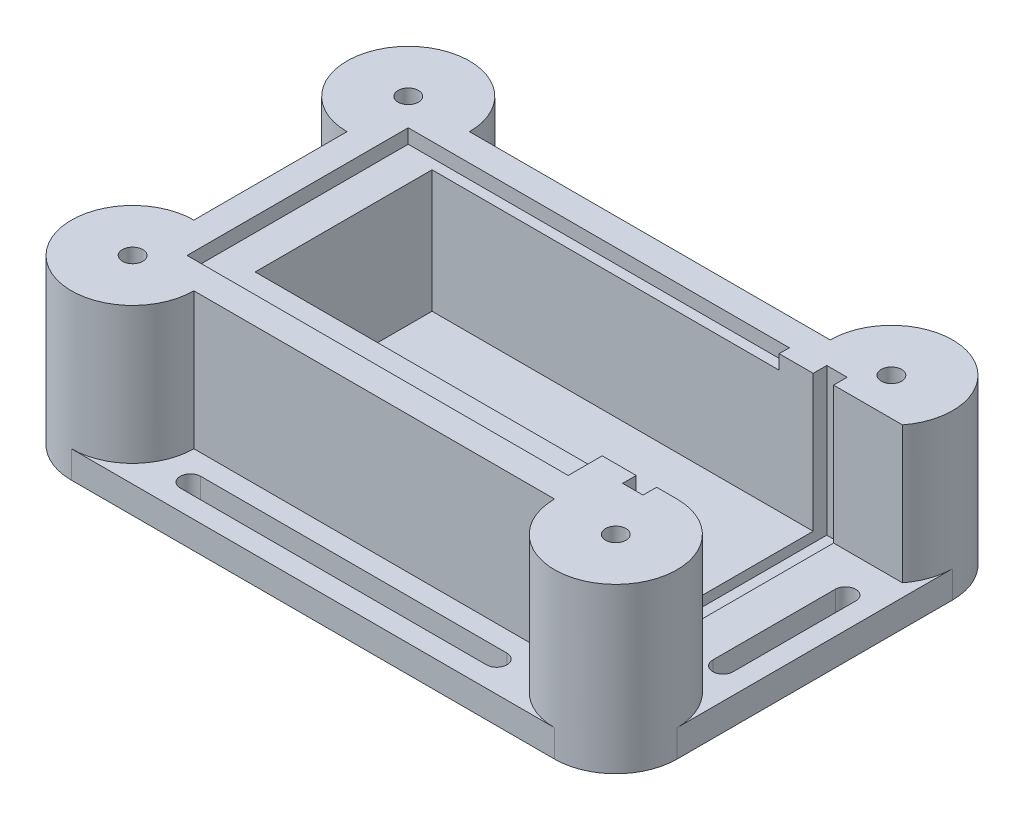
from build123d import *

# Parameters (mm, degrees)
BOSS_EXTRUDE1_DEPTH = 56
SKETCH2_W           = 40.5
SKETCH2_H           = 24.1
BOSS_EXTRUDE2_DEPTH = 4
SKETCH3_W           = 26
SKETCH3_H           = 18
BOSS_EXTRUDE4_DEPTH = 5
BOSS_EXTRUDE5_DEPTH = 11
SKETCH6_W           = 3
SKETCH6_H           = 30
CUT_EXTRUDE1_DEPTH  = 21.6
BOSS_EXTRUDE6_DEPTH = 24.1
BOSS_EXTRUDE7_DEPTH = 4
SKETCH9_R           = 1.5
CUT_EXTRUDE2_DEPTH  = 20


with BuildPart() as part:
    # Sketch1 → Boss-Extrude1 (new body)
    with BuildSketch(Plane(origin=(0, 0, 0), x_dir=(0, 0, -1), z_dir=(1, 0, 0))):
        Polygon((0, 0), (0, -18), (26, -18), (26, 0), (27.5, 0), (27.5, 2.1), (31.5, 2.1), (31.5, -22), (-9, -22), (-9, 2.1), (-5, 2.1), (-5, 0), align=None)
    extrude(amount=-BOSS_EXTRUDE1_DEPTH)

    # Sketch2 → Boss-Extrude2 (add)
    with BuildSketch(Plane.ZY.offset(56)):
        with Locations((-11.25, -9.95)):
            Rectangle(SKETCH2_W, SKETCH2_H)
    extrude(amount=BOSS_EXTRUDE2_DEPTH)

    # Sketch3 → Boss-Extrude4 (add)
    with BuildSketch(Plane(origin=(-56, 0, 0), x_dir=(0, 0, -1), z_dir=(1, 0, 0))):
        with Locations((13, -9)):
            Rectangle(SKETCH3_W, SKETCH3_H)
    extrude(amount=BOSS_EXTRUDE4_DEPTH)

    # Sketch5 → Boss-Extrude5 (add)
    with BuildSketch(Plane(origin=(0, 0, 0), x_dir=(0, 0, -1), z_dir=(1, 0, 0))):
        Polygon((0, 0), (0, 2.1), (-5, 2.1), (-9, 2.1), (-9, -22), (31.5, -22), (31.5, 2.1), (27.5, 2.1), (26, 2.1), (26, 0), (26, -18), (0, -18), align=None)
    extrude(amount=BOSS_EXTRUDE5_DEPTH)

    # Sketch6 → Cut-Extrude1 (cut)
    with BuildSketch(Plane(origin=(0, 2.1, 0), x_dir=(1, 0, 0), z_dir=(0, 1, 0))):
        with Locations((6.5, 13)):
            Rectangle(SKETCH6_W, SKETCH6_H)
    extrude(amount=-CUT_EXTRUDE1_DEPTH, mode=Mode.SUBTRACT)

    # Sketch7 → Boss-Extrude6 (add)
    with BuildSketch(Plane.XZ.offset(22)):
        with BuildLine():
            Line((-60, -22.5), (-60, -31.5))
            Line((-60, -31.5), (-51, -31.5))
            ThreePointArc((-51, -31.5), (-66.363961031, -37.863961031), (-60, -22.5))
        make_face()
        with BuildLine():
            Line((2, -31.5), (11, -31.5))
            Line((11, -31.5), (11, -26))
            Line((11, -26), (18.123903424, -26))
            ThreePointArc((18.123903424, -26), (13.905586789, -40.018072869), (2, -31.5))
        make_face()
        with BuildLine():
            Line((-60, 0), (-60, 9))
            Line((-60, 9), (-51, 9))
            ThreePointArc((-51, 9), (-66.363961031, 15.363961031), (-60, 0))
        make_face()
        with BuildLine():
            Line((2, 9), (11, 9))
            Line((11, 9), (11, 0))
            ThreePointArc((11, 0), (17.363961031, 15.363961031), (2, 9))
        make_face()
    extrude(amount=-BOSS_EXTRUDE6_DEPTH)

    # Sketch8 → Boss-Extrude7 (add)
    with BuildSketch(Plane.XZ.offset(22)):
        with BuildLine():
            Line((11, 18), (-60, 18))
            ThreePointArc((-60, 18), (-53.636038969, 15.363961031), (-51, 9))
            Line((-51, 9), (2, 9))
            ThreePointArc((2, 9), (4.636038969, 15.363961031), (11, 18))
        make_face()
        with BuildLine():
            ThreePointArc((-47, 12), (-48.5, 13.5), (-47, 15))
            Line((-47, 15), (-2, 15))
            ThreePointArc((-2, 15), (-0.5, 13.5), (-2, 12))
            Line((-2, 12), (-47, 12))
        make_face(mode=Mode.SUBTRACT)
        with BuildLine():
            Line((20, -31.5), (20, 9))
            ThreePointArc((20, 9), (17.363961031, 2.636038969), (11, 0))
            Line((11, 0), (11, -26))
            Line((11, -26), (18.123903424, -26))
            ThreePointArc((18.123903424, -26), (19.518072869, -28.594413211), (20, -31.5))
        make_face()
        with BuildLine():
            ThreePointArc((14, -2.25), (15.5, -0.75), (17, -2.25))
            Line((17, -2.25), (17, -20.25))
            ThreePointArc((17, -20.25), (15.5, -21.75), (14, -20.25))
            Line((14, -20.25), (14, -2.25))
        make_face(mode=Mode.SUBTRACT)
        with BuildLine():
            ThreePointArc((-51, -31.5), (-53.636038969, -37.863961031), (-60, -40.5))
            Line((-60, -40.5), (11, -40.5))
            ThreePointArc((11, -40.5), (4.636038969, -37.863961031), (2, -31.5))
            Line((2, -31.5), (-51, -31.5))
        make_face()
        with BuildLine():
            ThreePointArc((-47, -37.5), (-48.5, -36), (-47, -34.5))
            Line((-47, -34.5), (-2, -34.5))
            ThreePointArc((-2, -34.5), (-0.5, -36), (-2, -37.5))
            Line((-2, -37.5), (-47, -37.5))
        make_face(mode=Mode.SUBTRACT)
        with BuildLine():
            ThreePointArc((-60, 0), (-66.363961031, 2.636038969), (-69, 9))
            Line((-69, 9), (-69, -31.5))
            ThreePointArc((-69, -31.5), (-66.363961031, -25.136038969), (-60, -22.5))
            Line((-60, -22.5), (-60, 0))
        make_face()
        with BuildLine():
            ThreePointArc((-63, -20.25), (-64.5, -21.75), (-66, -20.25))
            Line((-66, -20.25), (-66, -2.25))
            ThreePointArc((-66, -2.25), (-64.5, -0.75), (-63, -2.25))
            Line((-63, -2.25), (-63, -20.25))
        make_face(mode=Mode.SUBTRACT)
    extrude(amount=-BOSS_EXTRUDE7_DEPTH)

    # Sketch9 → Cut-Extrude2 (cut)
    with BuildSketch(Plane(origin=(0, 2.1, 0), x_dir=(1, 0, 0), z_dir=(0, 1, 0))):
        with Locations((11, 31.5)):
            Circle(SKETCH9_R)
        with Locations((-60, 31.5)):
            Circle(SKETCH9_R)
        with Locations((-60, -9)):
            Circle(SKETCH9_R)
        with Locations((11, -9)):
            Circle(SKETCH9_R)
    extrude(amount=-CUT_EXTRUDE2_DEPTH, mode=Mode.SUBTRACT)


solid = part.part
